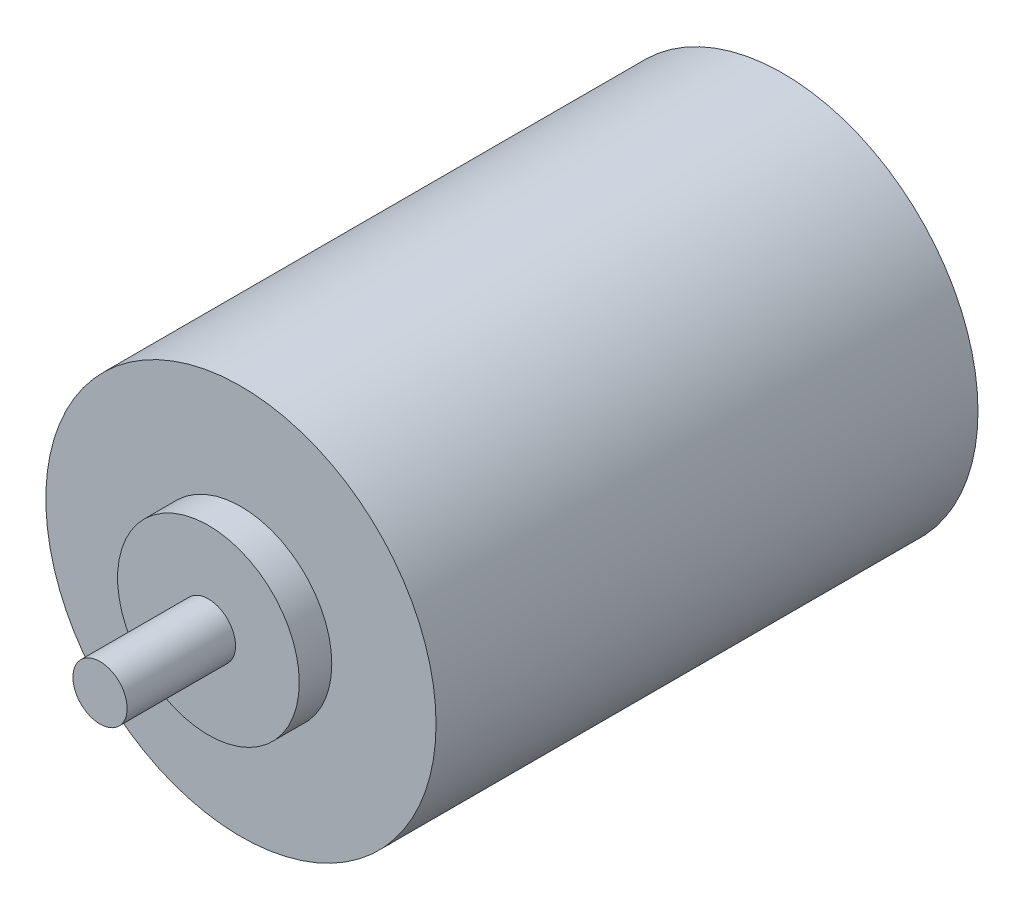
from build123d import *

# Parameters (mm, degrees)
SKETCH1_R           = 18
BOSS_EXTRUDE1_DEPTH = 50
SKETCH2_R           = 8.380776787
BOSS_EXTRUDE2_DEPTH = 3
SKETCH3_R           = 2.5
BOSS_EXTRUDE3_DEPTH = 10


with BuildPart() as part:
    # Sketch1 → Boss-Extrude1 (new body)
    with BuildSketch(Plane.XY):
        Circle(SKETCH1_R)
    extrude(amount=BOSS_EXTRUDE1_DEPTH)

    # Sketch2 → Boss-Extrude2 (add)
    with BuildSketch(Plane.XY.offset(50)):
        Circle(SKETCH2_R)
    extrude(amount=BOSS_EXTRUDE2_DEPTH)

    # Sketch3 → Boss-Extrude3 (add)
    with BuildSketch(Plane.XY.offset(53)):
        Circle(SKETCH3_R)
    extrude(amount=BOSS_EXTRUDE3_DEPTH)


solid = part.part
